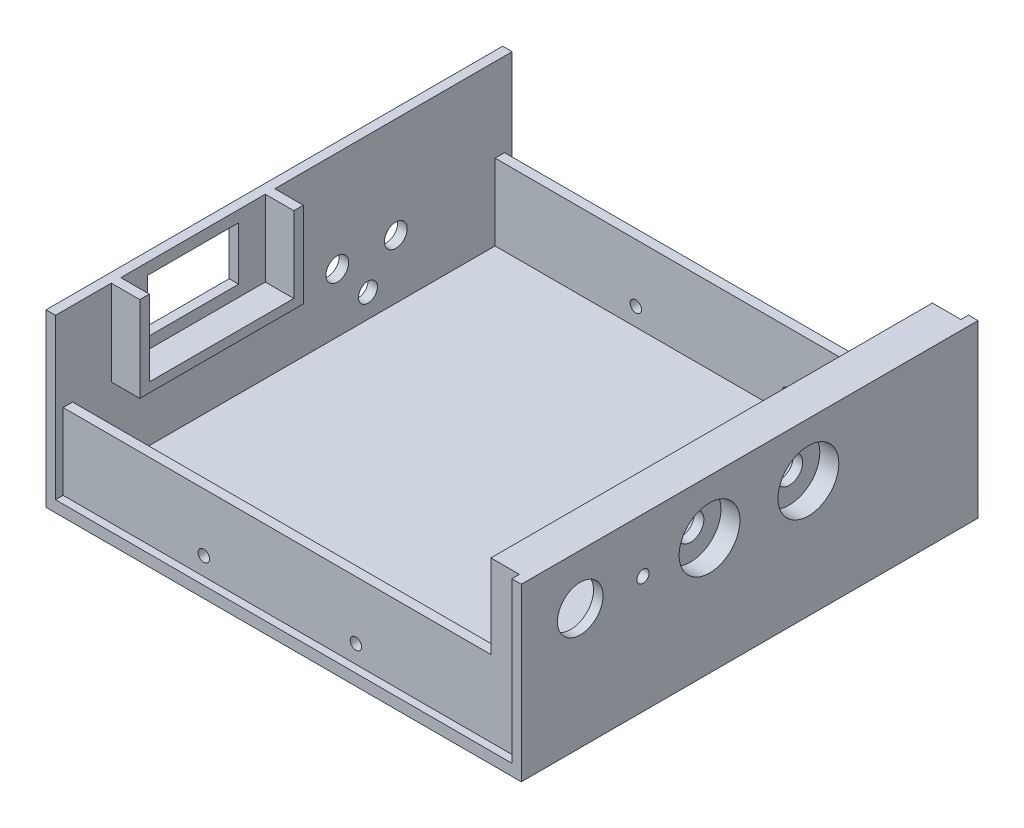
from build123d import *

# Parameters (mm, degrees)
SKETCH2_W                = 125
SKETCH2_H                = 120.1
BOSS_EXTRUDE1_DEPTH      = 45
SKETCH3_W                = 120
SKETCH3_H                = 111.1
CUT_EXTRUDE1_DEPTH       = 39
SKETCH4_W                = 120
SKETCH4_H                = 2
CUT_EXTRUDE3_DEPTH       = 43
LPATTERN1_COUNT          = 2
LPATTERN1_PITCH          = 118.1
SKETCH9_W                = 112.5
SKETCH9_H                = 116.1
CUT_EXTRUDE6_DEPTH       = 23
SKETCH11_R               = 3
CUT_EXTRUDE7_DEPTH       = 3.5
SKETCH15_R               = 2.5
CUT_EXTRUDE9_DEPTH       = 3.5
SKETCH13_W               = 24
SKETCH13_H               = 14
CUT_EXTRUDE10_DEPTH      = 3.5
BOSS_EXTRUDE3_DEPTH      = 7.5
BOSS_EXTRUDE4_DEPTH      = 10
LPATTERN3_COUNT          = 2
LPATTERN3_PITCH          = 26
SKETCH22_R               = 3.5
CUT_EXTRUDE11_DEPTH      = 10
LPATTERN4_COUNT          = 2
LPATTERN4_PITCH          = 26
SKETCH23_R               = 1.6
CUT_EXTRUDE12_DEPTH      = 10
SKETCH26_R               = 3.5
BOSS_EXTRUDE10_DEPTH     = 7.5
LPATTERN9_COUNT          = 2
LPATTERN9_PITCH          = 26
SKETCH27_R               = 6
CUT_EXTRUDE13_DEPTH      = 7.5
SKETCH28_R               = 1.5
CUT_EXTRUDE14_DEPTH      = 61.05
CUT_EXTRUDE14_DEPTH_BACK = 61.05
SKETCH30_R               = 8
CUT_EXTRUDE15_DEPTH      = 5
LPATTERN10_COUNT         = 2
LPATTERN10_PITCH         = 26


with BuildPart() as part:
    # Sketch2 → Boss-Extrude1 (new body)
    with BuildSketch(Plane(origin=(0, 0, 0), x_dir=(1, 0, 0), z_dir=(0, 1, 0))):
        Rectangle(SKETCH2_W, SKETCH2_H)
    extrude(amount=BOSS_EXTRUDE1_DEPTH)

    # Sketch3 → Cut-Extrude1 (cut)
    with BuildSketch(Plane(origin=(0, 3, 0), x_dir=(1, 0, 0), z_dir=(0, 1, 0))):
        Rectangle(SKETCH3_W, SKETCH3_H)
    extrude(amount=CUT_EXTRUDE1_DEPTH, mode=Mode.SUBTRACT)

    # Sketch4 → Cut-Extrude3 (cut, through all)
    with BuildSketch(Plane(origin=(0, 3, 0), x_dir=(1, 0, 0), z_dir=(0, 1, 0))):
        with Locations((0, -59.05)):
            Rectangle(SKETCH4_W, SKETCH4_H)
    cut_extrude3 = extrude(amount=CUT_EXTRUDE3_DEPTH, mode=Mode.SUBTRACT)

    # LPattern1: Cut-Extrude3 ×2
    with Locations(*[(0, 0, -i * LPATTERN1_PITCH) for i in range(1, LPATTERN1_COUNT)]):
        add(cut_extrude3, mode=Mode.SUBTRACT)

    # Sketch9 → Cut-Extrude6 (cut, through all)
    with BuildSketch(Plane(origin=(0, 23, 0), x_dir=(1, 0, 0), z_dir=(0, 1, 0))):
        with Locations((-3.75, 0)):
            Rectangle(SKETCH9_W, SKETCH9_H)
    extrude(amount=CUT_EXTRUDE6_DEPTH, mode=Mode.SUBTRACT)

    # Sketch11 → Cut-Extrude7 (cut, through all)
    with BuildSketch(Plane(origin=(-60, 0, 0), x_dir=(0, 0, -1), z_dir=(1, 0, 0))):
        with Locations((29.45, 18.51)):
            Circle(SKETCH11_R)
        with Locations((14.05, 18.51)):
            Circle(SKETCH11_R)
    extrude(amount=-CUT_EXTRUDE7_DEPTH, mode=Mode.SUBTRACT)

    # Sketch15 → Cut-Extrude9 (cut, through all)
    with BuildSketch(Plane(origin=(-60, 0, 0), x_dir=(0, 0, -1), z_dir=(1, 0, 0))):
        with Locations((22.117427494, 9.198406991)):
            Circle(SKETCH15_R)
    extrude(amount=-CUT_EXTRUDE9_DEPTH, mode=Mode.SUBTRACT)

    # Sketch13 → Cut-Extrude10 (cut, through all)
    with BuildSketch(Plane(origin=(-60, 0, 0), x_dir=(0, 0, -1), z_dir=(1, 0, 0))):
        with Locations((-23.885447562, 35)):
            Rectangle(SKETCH13_W, SKETCH13_H)
    extrude(amount=-CUT_EXTRUDE10_DEPTH, mode=Mode.SUBTRACT)

    # Sketch17 → Boss-Extrude3 (add)
    with BuildSketch(Plane(origin=(-60, 0, 0), x_dir=(0, 0, -1), z_dir=(1, 0, 0))):
        Polygon((-42.885447562, 45), (-42.885447562, 25), (-4.885447562, 25), (-4.885447562, 45), (-2.385447562, 45), (-2.385447562, 22.5), (-45.385447562, 22.5), (-45.385447562, 45), align=None)
    extrude(amount=BOSS_EXTRUDE3_DEPTH)

    # Sketch18 → Boss-Extrude4 (add)
    with BuildSketch(Plane(origin=(62.5, 0, 0), x_dir=(0, 0, -1), z_dir=(1, 0, 0))):
        with BuildLine():
            Line((7.45, 30.801411804), (7.45, 14.801411804))
            Line((7.45, 14.801411804), (4.95, 14.801411804))
            Line((4.95, 14.801411804), (4.95, 30.801411804))
            ThreePointArc((4.95, 30.801411804), (15.45, 41.301411804), (25.95, 30.801411804))
            Line((25.95, 30.801411804), (25.95, 14.801411804))
            Line((25.95, 14.801411804), (23.45, 14.801411804))
            Line((23.45, 14.801411804), (23.45, 30.801411804))
            ThreePointArc((23.45, 30.801411804), (15.45, 38.801411804), (7.45, 30.801411804))
        make_face()
    boss_extrude4 = extrude(amount=-BOSS_EXTRUDE4_DEPTH)

    # LPattern3: Boss-Extrude4 ×2
    with Locations(*[(0, 0, i * LPATTERN3_PITCH) for i in range(1, LPATTERN3_COUNT)]):
        add(boss_extrude4)

    # Sketch22 → Cut-Extrude11 (cut)
    with BuildSketch(Plane(origin=(62.5, 0, 0), x_dir=(0, 0, -1), z_dir=(1, 0, 0))):
        with Locations((15.45, 30.801411804)):
            Circle(SKETCH22_R)
    cut_extrude11 = extrude(amount=-CUT_EXTRUDE11_DEPTH, mode=Mode.SUBTRACT)

    # LPattern4: Cut-Extrude11 ×2
    with Locations(*[(0, 0, i * LPATTERN4_PITCH) for i in range(1, LPATTERN4_COUNT)]):
        add(cut_extrude11, mode=Mode.SUBTRACT)

    # Sketch23 → Cut-Extrude12 (cut)
    with BuildSketch(Plane(origin=(62.5, 0, 0), x_dir=(0, 0, -1), z_dir=(1, 0, 0))):
        with Locations((-28.05, 30.801411804)):
            Circle(SKETCH23_R)
    extrude(amount=-CUT_EXTRUDE12_DEPTH, mode=Mode.SUBTRACT)

    # Sketch26 → Boss-Extrude10 (add)
    with BuildSketch(Plane(origin=(62.5, 0, 0), x_dir=(0, 0, -1), z_dir=(1, 0, 0))):
        with BuildLine():
            Line((23.45, 14.801411804), (7.45, 14.801411804))
            Line((7.45, 14.801411804), (7.45, 30.801411804))
            ThreePointArc((7.45, 30.801411804), (15.45, 38.801411804), (23.45, 30.801411804))
            Line((23.45, 30.801411804), (23.45, 14.801411804))
        make_face()
        with Locations((15.45, 30.801411804)):
            Circle(SKETCH26_R, mode=Mode.SUBTRACT)
    boss_extrude10 = extrude(amount=-BOSS_EXTRUDE10_DEPTH)

    # LPattern9: Boss-Extrude10 ×2
    with Locations(*[(0, 0, i * LPATTERN9_PITCH) for i in range(1, LPATTERN9_COUNT)]):
        add(boss_extrude10)

    # Sketch27 → Cut-Extrude13 (cut)
    with BuildSketch(Plane(origin=(62.5, 0, 0), x_dir=(0, 0, -1), z_dir=(1, 0, 0))):
        with Locations((-44.552239633, 31.709599536)):
            Circle(SKETCH27_R)
    extrude(amount=-CUT_EXTRUDE13_DEPTH, mode=Mode.SUBTRACT)

    # Sketch28 → Cut-Extrude14 (cut, two sides)
    with BuildSketch(Plane.XY) as cut_extrude14_sk:
        with Locations((-23, 7.75)):
            Circle(SKETCH28_R)
        with Locations((17, 7.75)):
            Circle(SKETCH28_R)
    extrude(amount=CUT_EXTRUDE14_DEPTH, mode=Mode.SUBTRACT)
    extrude(cut_extrude14_sk.sketch, amount=-CUT_EXTRUDE14_DEPTH_BACK, mode=Mode.SUBTRACT)

    # Sketch30 → Cut-Extrude15 (cut)
    with BuildSketch(Plane(origin=(62.5, 0, 0), x_dir=(0, 0, -1), z_dir=(1, 0, 0))):
        with Locations((15.45, 30.801411804)):
            Circle(SKETCH30_R)
    cut_extrude15 = extrude(amount=-CUT_EXTRUDE15_DEPTH, mode=Mode.SUBTRACT)

    # LPattern10: Cut-Extrude15 ×2
    with Locations(*[(0, 0, i * LPATTERN10_PITCH) for i in range(1, LPATTERN10_COUNT)]):
        add(cut_extrude15, mode=Mode.SUBTRACT)


solid = part.part
